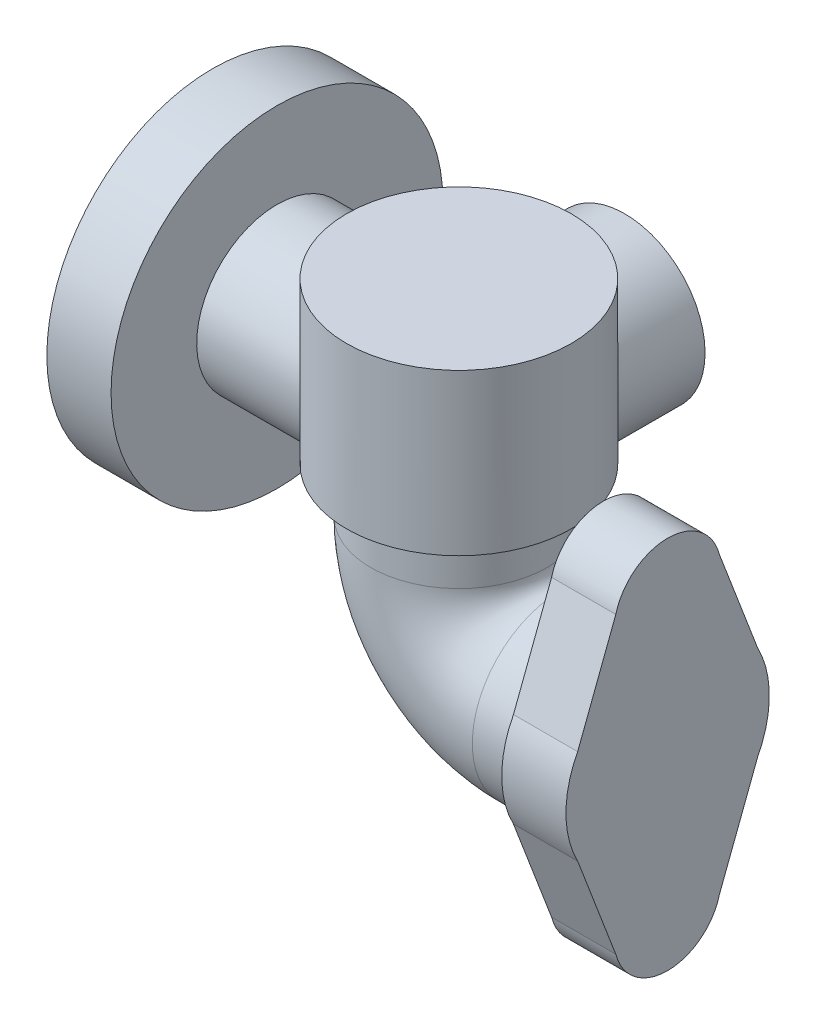
from build123d import *

# Parameters (mm, degrees)
SKETCH2_W           = 42
SKETCH2_H           = 60
SKETCH3_R           = 33
BOSS_EXTRUDE1_DEPTH = 24
SKETCH6_W           = 62
SKETCH6_H           = 30


with BuildPart() as part:
    # Sketch1 → Revolve1 (revolve)
    with BuildSketch(Plane.XY):
        Polygon((-92, 0), (-92, 62), (-68, 62), (-68, 30), (0, 30), (0, 0), align=None)
    revolve(axis=Axis((0, 0, 0), (-1, 0, 0)))

    # Sketch2 → Revolve2 (revolve)
    with BuildSketch(Plane(origin=(0, 0, 0), x_dir=(0, 0, -1), z_dir=(1, 0, 0))):
        with Locations((21, 10)):
            Rectangle(SKETCH2_W, SKETCH2_H)
    revolve(axis=Axis((0, 40, 0), (0, -1, 0)))

    # Sweep1: sweep along a path in Sketch4
    with BuildLine(Plane.XY) as sweep1_path:
        Line((0, -20), (0, -37))
        ThreePointArc((0, -37), (11.129942315, -63.870057685), (38, -75))
        Line((38, -75), (78, -75))
    # Sketch3 → Sweep1 (sweep)
    with BuildSketch(Plane.XZ.offset(20)):
        Circle(SKETCH3_R)
    sweep(path=sweep1_path.line)

    # Sketch5 → Boss-Extrude1 (add)
    with BuildSketch(Plane(origin=(78, 0, 0), x_dir=(0, 0, -1), z_dir=(1, 0, 0))):
        with BuildLine():
            Line((-19.364916731, -20), (-33.616565645, -57.282028495))
            ThreePointArc((-33.616565645, -57.282028495), (-38, -75), (-33.616565645, -92.717971505))
            Line((-33.616565645, -92.717971505), (-19.364916731, -130))
            ThreePointArc((-19.364916731, -130), (0, -145), (19.364916731, -130))
            Line((19.364916731, -130), (33.616565645, -92.717971505))
            ThreePointArc((33.616565645, -92.717971505), (38, -75), (33.616565645, -57.282028495))
            Line((33.616565645, -57.282028495), (19.364916731, -20))
            ThreePointArc((19.364916731, -20), (0, -5), (-19.364916731, -20))
        make_face()
    extrude(amount=-BOSS_EXTRUDE1_DEPTH)

    # Sketch6 → Revolve3 (revolve)
    with BuildSketch(Plane(origin=(0, 0, 0), x_dir=(0, 0, -1), z_dir=(1, 0, 0))):
        with Locations((31, 15)):
            Rectangle(SKETCH6_W, SKETCH6_H)
    revolve(axis=Axis((0, 0, 0), (0, 0, -1)))


solid = part.part
